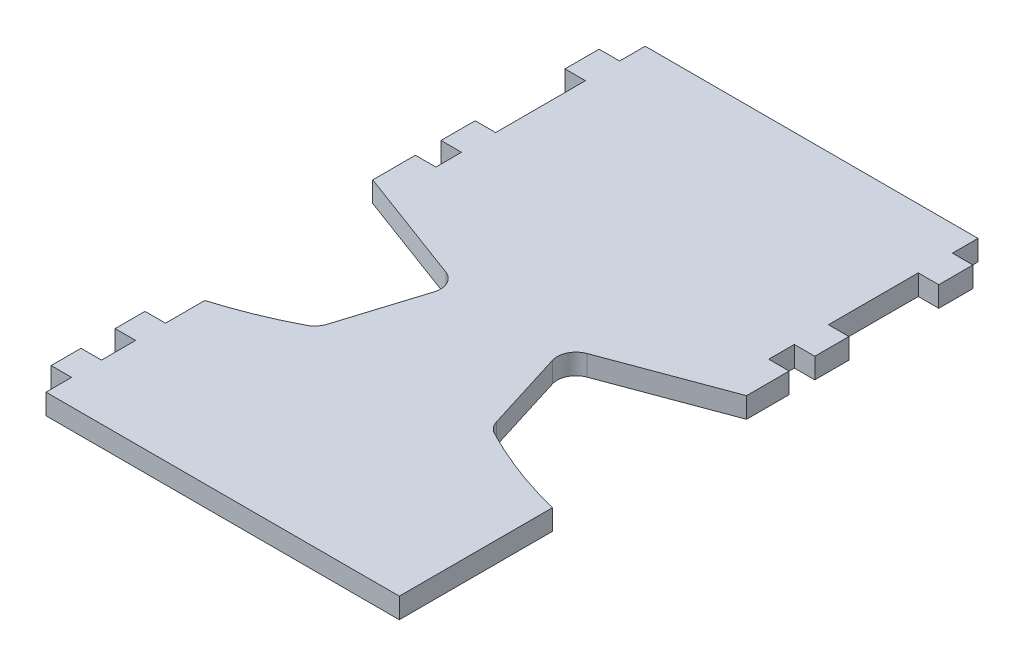
from build123d import *

# Parameters (mm, degrees)
BOSS_EXTRUDE1_DEPTH = 3.048


with BuildPart() as part:
    # Sketch1 → Boss-Extrude1 (new, symmetric)
    with BuildSketch(Plane(origin=(0, 0, 0), x_dir=(1, 0, 0), z_dir=(0, 1, 0))):
        with BuildLine():
            Line((-49.53, 45.72), (49.53, 45.72))
            Line((49.53, 45.72), (49.53, 38.1))
            Line((49.53, 38.1), (55.626, 38.1))
            Line((55.626, 38.1), (55.626, 27.94))
            Line((55.626, 27.94), (49.53, 27.94))
            Line((49.53, 27.94), (49.53, 1.208143374))
            Line((49.53, 1.208143374), (55.626, 1.208143374))
            Line((55.626, 1.208143374), (55.626, -8.951856626))
            Line((55.626, -8.951856626), (49.53, -8.951856626))
            Line((49.53, -8.951856626), (49.53, -16.571856626))
            Line((49.53, -16.571856626), (55.626, -16.571856626))
            Line((55.626, -16.571856626), (55.626, -29.271856626))
            Line((55.626, -29.271856626), (21.019827136, -42.136821893))
            ThreePointArc((21.019827136, -42.136821893), (17.95098831, -44.911778638), (17.631953735, -49.036869377))
            Line((17.631953735, -49.036869377), (25.187729856, -73.287029113))
            ThreePointArc((25.187729856, -73.287029113), (26.234780075, -75.207903536), (27.939063878, -76.579577488))
            ThreePointArc((27.939063878, -76.579577488), (41.468907088, -82.632484358), (55.626, -87.022365809))
            Line((55.626, -87.022365809), (55.626, -132.617292876))
            Line((55.626, -132.617292876), (-49.53, -132.617292876))
            Line((-49.53, -132.617292876), (-49.53, -124.997292876))
            Line((-49.53, -124.997292876), (-55.626, -124.997292876))
            Line((-55.626, -124.997292876), (-55.626, -116.107292876))
            Line((-55.626, -116.107292876), (-49.53, -116.107292876))
            Line((-49.53, -116.107292876), (-49.53, -105.947292876))
            Line((-49.53, -105.947292876), (-55.626, -105.947292876))
            Line((-55.626, -105.947292876), (-55.626, -97.057292876))
            Line((-55.626, -97.057292876), (-49.53, -97.057292876))
            Line((-49.53, -97.057292876), (-49.53, -85.359826344))
            ThreePointArc((-49.53, -85.359826344), (-38.527111219, -81.479756652), (-27.939063878, -76.579577488))
            ThreePointArc((-27.939063878, -76.579577488), (-26.234780075, -75.207903536), (-25.187729856, -73.287029113))
            Line((-25.187729856, -73.287029113), (-17.631953735, -49.036869377))
            ThreePointArc((-17.631953735, -49.036869377), (-17.95098831, -44.911778638), (-21.019827136, -42.136821893))
            Line((-21.019827136, -42.136821893), (-55.626, -29.271856626))
            Line((-55.626, -29.271856626), (-55.626, -16.571856626))
            Line((-55.626, -16.571856626), (-49.53, -16.571856626))
            Line((-49.53, -16.571856626), (-49.53, -8.951856626))
            Line((-49.53, -8.951856626), (-55.626, -8.951856626))
            Line((-55.626, -8.951856626), (-55.626, 1.208143374))
            Line((-55.626, 1.208143374), (-49.53, 1.208143374))
            Line((-49.53, 1.208143374), (-49.53, 27.94))
            Line((-49.53, 27.94), (-55.626, 27.94))
            Line((-55.626, 27.94), (-55.626, 38.1))
            Line((-55.626, 38.1), (-49.53, 38.1))
            Line((-49.53, 38.1), (-49.53, 45.72))
        make_face()
    extrude(amount=BOSS_EXTRUDE1_DEPTH, both=True)


solid = part.part
